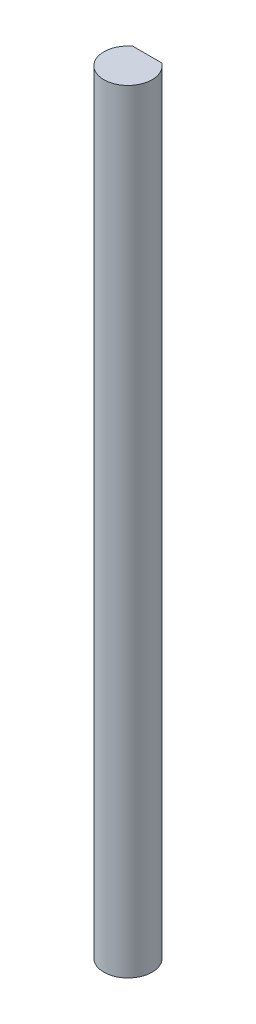
from build123d import *

# Parameters (mm, degrees)
BOSS_EXTRUDE1_DEPTH = 101.6


with BuildPart() as part:
    # Sketch1 → Boss-Extrude1 (new body)
    with BuildSketch(Plane(origin=(0, 0, 0), x_dir=(1, 0, 0), z_dir=(0, 1, 0))):
        with BuildLine():
            Line((-1.905, 2.54), (1.905, 2.54))
            ThreePointArc((1.905, 2.54), (0, -3.175), (-1.905, 2.54))
        make_face()
    extrude(amount=BOSS_EXTRUDE1_DEPTH)


solid = part.part
